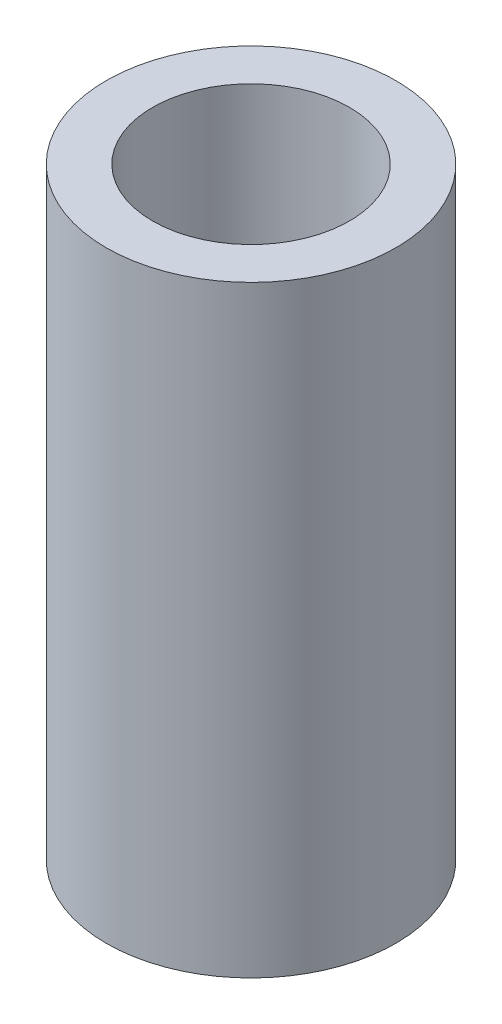
from build123d import *

# Parameters (mm, degrees)
SKETCH1_R           = 12.5
SKETCH1_R_2         = 8.5
BOSS_EXTRUDE1_DEPTH = 52


with BuildPart() as part:
    # Sketch1 → Boss-Extrude1 (new body)
    with BuildSketch(Plane(origin=(0, 0, 0), x_dir=(1, 0, 0), z_dir=(0, 1, 0))):
        Circle(SKETCH1_R)
        Circle(SKETCH1_R_2, mode=Mode.SUBTRACT)
    extrude(amount=BOSS_EXTRUDE1_DEPTH)


solid = part.part
